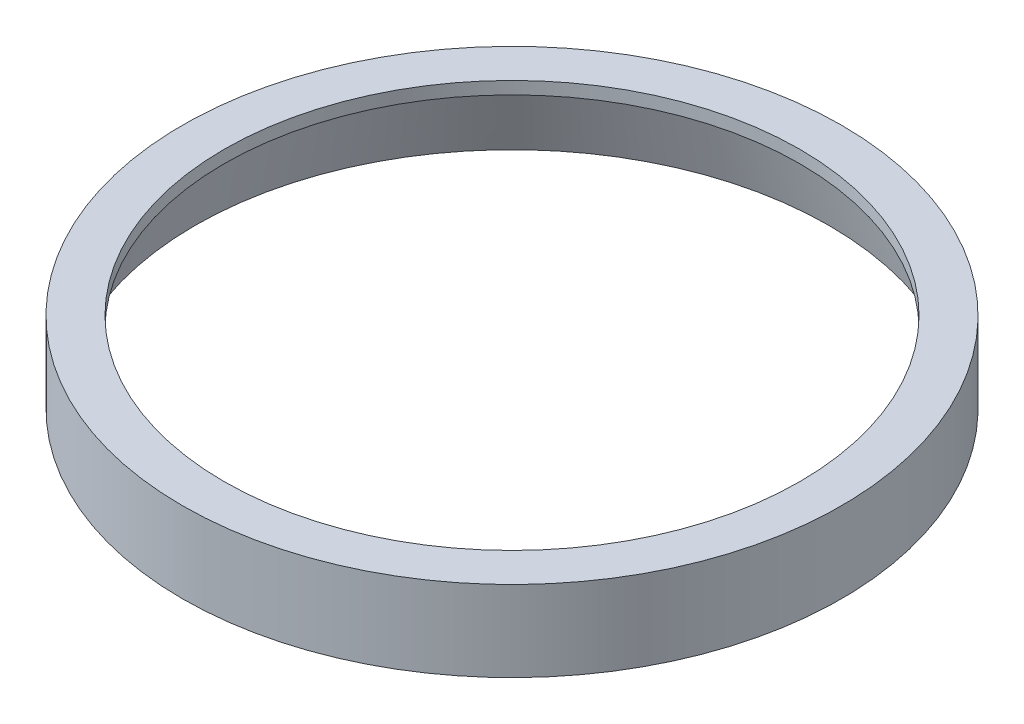
from build123d import *


with BuildPart() as part:
    # Sketch1 → Revolve1 (revolve)
    with BuildSketch(Plane.XY, mode=Mode.PRIVATE) as revolve1_sk:
        with BuildLine():
            Line((38, 2.333775441), (35.932797439, 10.048680429))
            ThreePointArc((35.932797439, 10.048680429), (35.251098838, 10.384502157), (34.5, 10.5))
            Line((34.5, 10.5), (34.5, 12))
            Line((34.5, 12), (39.5, 12))
            Line((39.5, 12), (39.5, 2.333775441))
            Line((39.5, 2.333775441), (38, 2.333775441))
        make_face()
    revolve(revolve1_sk.sketch.rotate(Axis((0, 0, 0), (0, 1, 0)), 90), axis=Axis((0, 0, 0), (0, 1, 0)))  # turned: the seam where the file's is


solid = part.part
